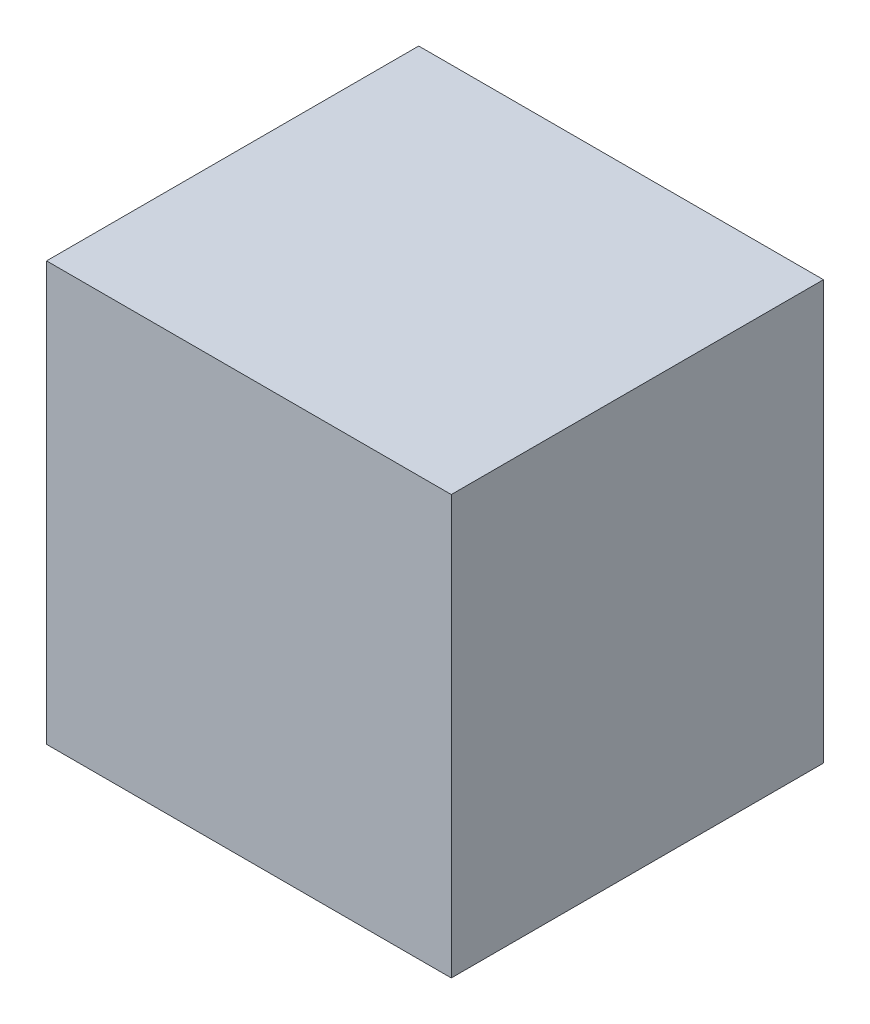
from build123d import *

# Parameters (mm, degrees)
SKETCH_1_W      = 435
SKETCH_1_H      = 450
EXTRUDE_1_DEPTH = 400


with BuildPart() as part:
    # 草图1 → 凸台-拉伸1 (new body)
    with BuildSketch(Plane.XY):
        with Locations((182.930010332, 215.424858977)):
            Rectangle(SKETCH_1_W, SKETCH_1_H)
    extrude(amount=EXTRUDE_1_DEPTH)


solid = part.part
